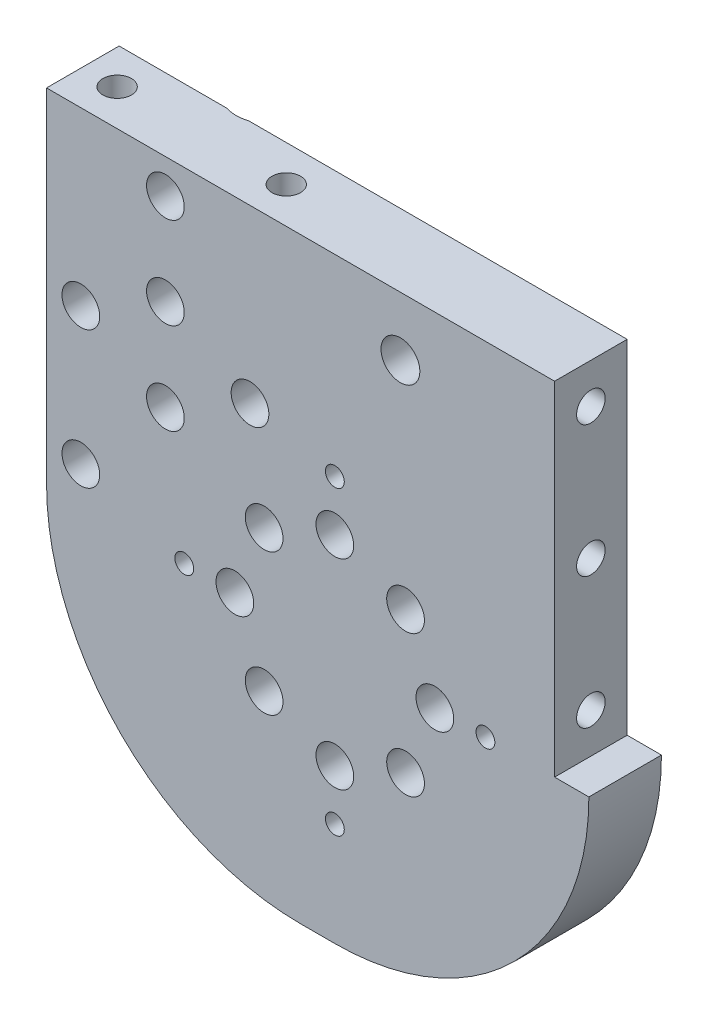
from build123d import *

# Parameters (mm, degrees)
BOSS_EXTRUDE1_DEPTH                                 = 12.7
F_4_CLEARANCE_HOLE1_D                               = 3.3
F_4_CLEARANCE_HOLE1_DEPTH                           = 12.7
F_1_4_CLEARANCE_HOLE1_D                             = 6.6
F_1_4_CLEARANCE_HOLE1_DEPTH                         = 12.7
F_1_4_CLEARANCE_HOLE2_D                             = 6.8
F_1_4_CLEARANCE_HOLE2_DEPTH                         = 12.7
CSK_FOR_1_4_FLAT_HEAD_MACHINE_SCREW_100_D           = 6.6
CSK_FOR_1_4_FLAT_HEAD_MACHINE_SCREW_100_DEPTH       = 12.7
CSK_FOR_1_4_FLAT_HEAD_MACHINE_SCREW_100_CSINK_D     = 12.6
CSK_FOR_1_4_FLAT_HEAD_MACHINE_SCREW_100_CSINK_ANGLE = 90
F_10_CLEARANCE_HOLE1_D                              = 5
F_10_CLEARANCE_HOLE1_DEPTH                          = 15
F_10_CLEARANCE_HOLE2_D                              = 5
F_10_CLEARANCE_HOLE2_DEPTH                          = 10
F_1_3_4_CLEARANCE_HOLE1_D                           = 45
F_1_3_4_CLEARANCE_HOLE1_DEPTH                       = 5
F_1_4_CLEARANCE_HOLE3_D                             = 6.6
F_1_4_CLEARANCE_HOLE3_DEPTH                         = 12.7
CHAMFER1_SIZE                                       = 3
BOSS_EXTRUDE2_DEPTH                                 = 12.7


with BuildPart() as part:
    # Sketch1 → Boss-Extrude1 (new body)
    with BuildSketch(Plane(origin=(0, 0, 0), x_dir=(-1, 0, 0), z_dir=(0, 0, -1))):
        with BuildLine():
            Line((44.45, 0), (44.45, 60))
            Line((44.45, 60), (-44.45, 60))
            Line((-44.45, 60), (-44.45, 0))
            ThreePointArc((-44.45, 0), (0, -44.45), (44.45, 0))
        make_face()
    extrude(amount=-BOSS_EXTRUDE1_DEPTH)

    # #4 Clearance Hole1
    with Locations(Plane.XY.offset(12.7)):
        with Locations((32.349998458, 0.009014041), (6, -26.35), (-20.349998115, -0.009967087), (6, 26.35)):
            Hole(F_4_CLEARANCE_HOLE1_D / 2, depth=F_4_CLEARANCE_HOLE1_DEPTH)

    # 1/4 Clearance Hole1
    with Locations(Plane(origin=(0, 0, 0), x_dir=(-1, 0, 0), z_dir=(0, 0, -1))):
        with Locations((8.85, 30), (23.65, 38), (23.65, 22)):
            Hole(F_1_4_CLEARANCE_HOLE1_D / 2, depth=F_1_4_CLEARANCE_HOLE1_DEPTH)

    # 1/4 Clearance Hole2
    with Locations(Plane.XY.offset(12.7)):
        with Locations((17.47250377, 49.692873304)):
            Hole(F_1_4_CLEARANCE_HOLE2_D / 2, depth=F_1_4_CLEARANCE_HOLE2_DEPTH)

    # CSK for 1/4 Flat Head Machine Screw (100)1
    with Locations(Plane(origin=(0, 0, 0), x_dir=(-1, 0, 0), z_dir=(0, 0, -1))):
        with Locations((23.65, 54), (38.45, 6), (38.45, 30)):
            CounterSinkHole(CSK_FOR_1_4_FLAT_HEAD_MACHINE_SCREW_100_D / 2, CSK_FOR_1_4_FLAT_HEAD_MACHINE_SCREW_100_CSINK_D / 2, depth=CSK_FOR_1_4_FLAT_HEAD_MACHINE_SCREW_100_DEPTH, counter_sink_angle=CSK_FOR_1_4_FLAT_HEAD_MACHINE_SCREW_100_CSINK_ANGLE)

    # #10 Clearance Hole1
    with Locations(Plane(origin=(0, 60, 0), x_dir=(1, 0, 0), z_dir=(0, 1, 0))):
        with Locations((-38.45, -6.35), (-8.85, -6.35)):
            Hole(F_10_CLEARANCE_HOLE1_D / 2, depth=F_10_CLEARANCE_HOLE1_DEPTH)

    # #10 Clearance Hole2
    with Locations(Plane(origin=(44.45, 0, 0), x_dir=(0, 0, -1), z_dir=(1, 0, 0))):
        with Locations((-6.35, 7), (-6.35, 53), (-6.35, 30)):
            Hole(F_10_CLEARANCE_HOLE2_D / 2, depth=F_10_CLEARANCE_HOLE2_DEPTH)

    # 1-3/4 Clearance Hole1
    with Locations(Plane(origin=(0, 0, 0), x_dir=(-1, 0, 0), z_dir=(0, 0, -1))):
        with Locations((-6, 0)):
            Hole(F_1_3_4_CLEARANCE_HOLE1_D / 2, depth=F_1_3_4_CLEARANCE_HOLE1_DEPTH)

    # 1/4 Clearance Hole3
    with Locations(Plane.XY.offset(12.7)):
        with Locations((18.374368671, 12.374368671), (23.499999956, -0.001247108), (18.374368671, -12.374368671), (6, -17.5), (-6.374368671, -12.374368671), (-11.5, 0), (-6.374368671, 12.374368671), (6, 17.5)):
            Hole(F_1_4_CLEARANCE_HOLE3_D / 2, depth=F_1_4_CLEARANCE_HOLE3_DEPTH)

    # Chamfer1
    chamfer1_edges = [part.edges().sort_by_distance(p)[0] for p in [
        (-26.95, 22, 0),
        (-26.95, 38, 0),
        (-12.15, 30, 0),
    ]]
    chamfer(chamfer1_edges, length=CHAMFER1_SIZE)

    # Sketch18 → Boss-Extrude2 (add)
    with BuildSketch(Plane(origin=(0, 0, 0), x_dir=(-1, 0, 0), z_dir=(0, 0, -1))):
        with BuildLine():
            Line((-44.45, 0), (-50.45, 0))
            ThreePointArc((-50.45, 0), (-37.430896424, -31.430896424), (-6, -44.45))
            Line((-6, -44.45), (0, -44.45))
            ThreePointArc((0, -44.45), (-31.430896424, -31.430896424), (-44.45, 0))
        make_face()
    extrude(amount=-BOSS_EXTRUDE2_DEPTH)


solid = part.part
